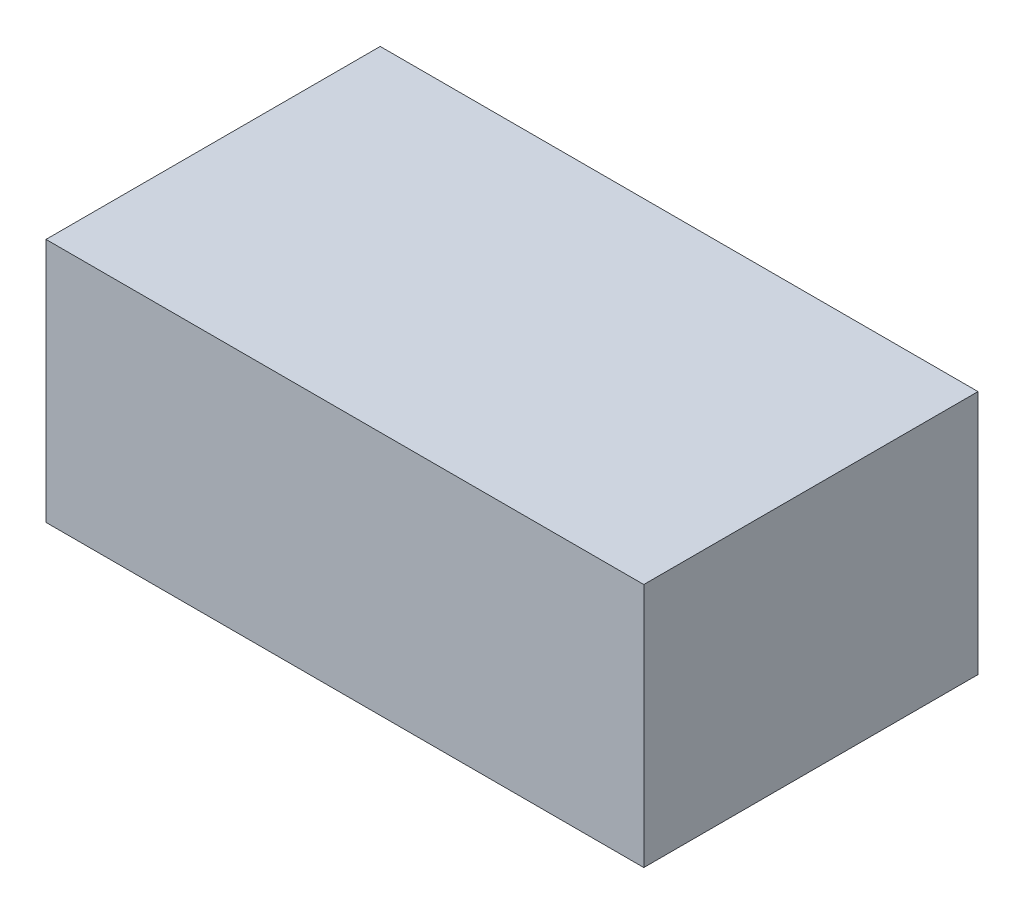
from build123d import *

# Parameters (mm, degrees)
SKETCH1_W           = 28.8036
SKETCH1_H           = 16.1036
BOSS_EXTRUDE1_DEPTH = 11.811


with BuildPart() as part:
    # Sketch1 → Boss-Extrude1 (new body)
    with BuildSketch(Plane(origin=(0, 0, 0), x_dir=(1, 0, 0), z_dir=(0, 1, 0))):
        Rectangle(SKETCH1_W, SKETCH1_H)
    extrude(amount=BOSS_EXTRUDE1_DEPTH)


solid = part.part
